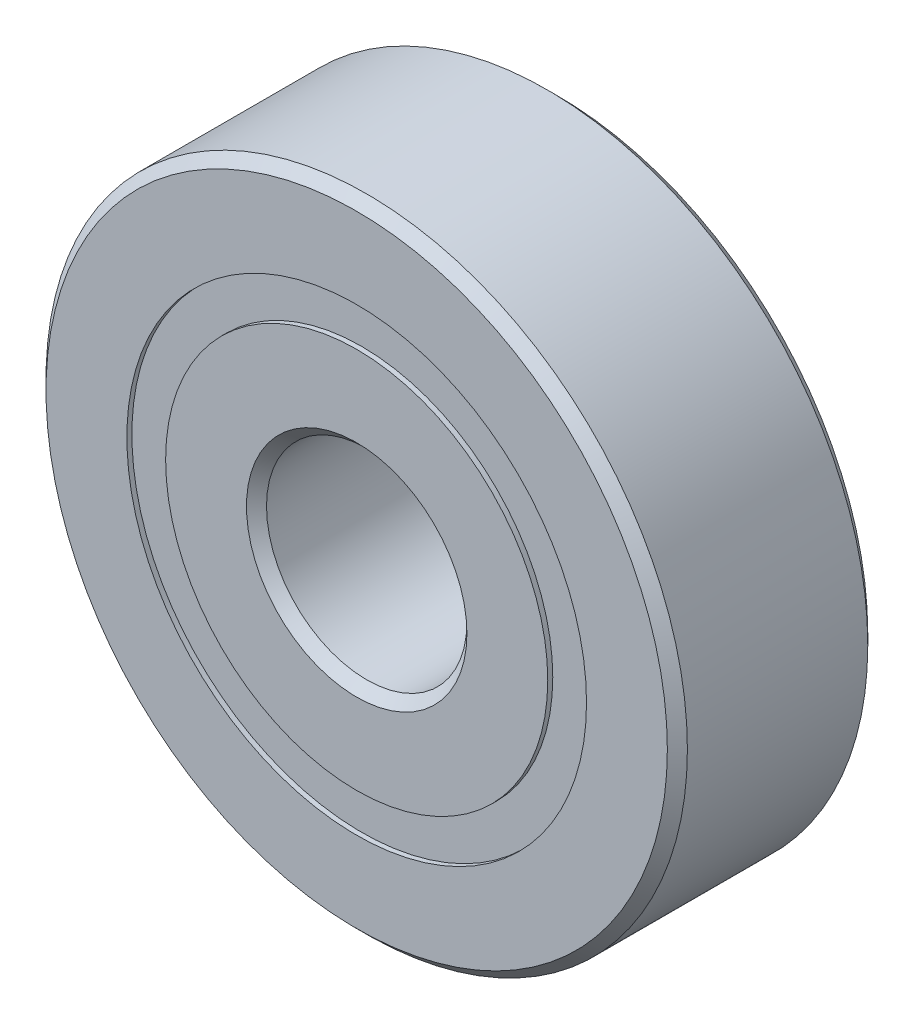
from build123d import *

# Parameters (mm, degrees)
CIRPATTERN1_COUNT = 12
SKETCH5_W         = 1.163242561
SKETCH5_H         = 0.967032968


with BuildPart() as part:
    # Sketch1 → Revolve1 (revolve)
    with BuildSketch(Plane(origin=(0, 0, 0), x_dir=(0, 0, -1), z_dir=(1, 0, 0))):
        with BuildLine():
            Line((2.25, 8), (-2.25, 8))
            Line((-2.25, 8), (-2.5, 7.75))
            Line((-2.5, 7.75), (-2.5, 5.733516484))
            Line((-2.5, 5.733516484), (-1.111111111, 5.733516484))
            ThreePointArc((-1.111111111, 5.733516484), (0, 6.461757439), (1.111111111, 5.733516484))
            Line((1.111111111, 5.733516484), (2.5, 5.733516484))
            Line((2.5, 5.733516484), (2.5, 7.75))
            Line((2.5, 7.75), (2.25, 8))
        make_face()
    revolve(axis=Axis((0, 0, 2.5), (0, 0, -1)))


with BuildPart() as body_2:
    # Sketch3 → Revolve3 (revolve)
    with BuildSketch(Plane(origin=(0, 0, 0), x_dir=(0, 0, -1), z_dir=(1, 0, 0))):
        with BuildLine():
            Line((-2.5, 4.766483516), (-1.111111111, 4.766483516))
            ThreePointArc((-1.111111111, 4.766483516), (0, 4.038242561), (1.111111111, 4.766483516))
            Line((1.111111111, 4.766483516), (2.5, 4.766483516))
            Line((2.5, 4.766483516), (2.5, 2.75))
            Line((2.5, 2.75), (2.25, 2.5))
            Line((2.25, 2.5), (-2.25, 2.5))
            Line((-2.25, 2.5), (-2.5, 2.75))
            Line((-2.5, 2.75), (-2.5, 4.766483516))
        make_face()
    revolve(axis=Axis((0, 0, 2.5), (0, 0, -1)))


with BuildPart() as body_3:
    # Sketch4 → Revolve4 (revolve)
    with BuildSketch(Plane(origin=(0, 0, 0), x_dir=(0, 0, -1), z_dir=(1, 0, 0))):
        with BuildLine():
            Line((-1.211757439, 5.25), (1.211757439, 5.25))
            ThreePointArc((1.211757439, 5.25), (0, 6.461757439), (-1.211757439, 5.25))
        make_face()
    revolve(axis=Axis((0, 5.25, 1.211757439), (0, 0, -1)))


with BuildPart() as cirpattern1_1:
    # CirPattern1: pattern copy
    add(body_3.part.rotate(Axis((0, 0, -2.5), (0, 0, 1)), 1 * 360 / CIRPATTERN1_COUNT))


with BuildPart() as cirpattern1_2:
    # CirPattern1: pattern copy
    add(body_3.part.rotate(Axis((0, 0, -2.5), (0, 0, 1)), 2 * 360 / CIRPATTERN1_COUNT))


with BuildPart() as cirpattern1_3:
    # CirPattern1: pattern copy
    add(body_3.part.rotate(Axis((0, 0, -2.5), (0, 0, 1)), 3 * 360 / CIRPATTERN1_COUNT))


with BuildPart() as cirpattern1_4:
    # CirPattern1: pattern copy
    add(body_3.part.rotate(Axis((0, 0, -2.5), (0, 0, 1)), 4 * 360 / CIRPATTERN1_COUNT))


with BuildPart() as cirpattern1_5:
    # CirPattern1: pattern copy
    add(body_3.part.rotate(Axis((0, 0, -2.5), (0, 0, 1)), 5 * 360 / CIRPATTERN1_COUNT))


with BuildPart() as cirpattern1_6:
    # CirPattern1: pattern copy
    add(body_3.part.rotate(Axis((0, 0, -2.5), (0, 0, 1)), 6 * 360 / CIRPATTERN1_COUNT))


with BuildPart() as cirpattern1_7:
    # CirPattern1: pattern copy
    add(body_3.part.rotate(Axis((0, 0, -2.5), (0, 0, 1)), 7 * 360 / CIRPATTERN1_COUNT))


with BuildPart() as cirpattern1_8:
    # CirPattern1: pattern copy
    add(body_3.part.rotate(Axis((0, 0, -2.5), (0, 0, 1)), 8 * 360 / CIRPATTERN1_COUNT))


with BuildPart() as cirpattern1_9:
    # CirPattern1: pattern copy
    add(body_3.part.rotate(Axis((0, 0, -2.5), (0, 0, 1)), 9 * 360 / CIRPATTERN1_COUNT))


with BuildPart() as cirpattern1_10:
    # CirPattern1: pattern copy
    add(body_3.part.rotate(Axis((0, 0, -2.5), (0, 0, 1)), 10 * 360 / CIRPATTERN1_COUNT))


with BuildPart() as cirpattern1_11:
    # CirPattern1: pattern copy
    add(body_3.part.rotate(Axis((0, 0, -2.5), (0, 0, 1)), 11 * 360 / CIRPATTERN1_COUNT))


with BuildPart() as body_15:
    # Sketch5 → Revolve5 (revolve)
    with BuildSketch(Plane(origin=(0, 0, 0), x_dir=(0, 0, -1), z_dir=(1, 0, 0))):
        with Locations((-1.79337872, 5.25)):
            Rectangle(SKETCH5_W, SKETCH5_H)
        with Locations((1.79337872, 5.25)):
            Rectangle(SKETCH5_W, SKETCH5_H)
    revolve(axis=Axis((0, 0, 2.5), (0, 0, -1)))


solid = Compound([part.part, body_2.part, body_3.part, cirpattern1_1.part, cirpattern1_2.part, cirpattern1_3.part, cirpattern1_4.part, cirpattern1_5.part, cirpattern1_6.part, cirpattern1_7.part, cirpattern1_8.part, cirpattern1_9.part, cirpattern1_10.part, cirpattern1_11.part, body_15.part])
